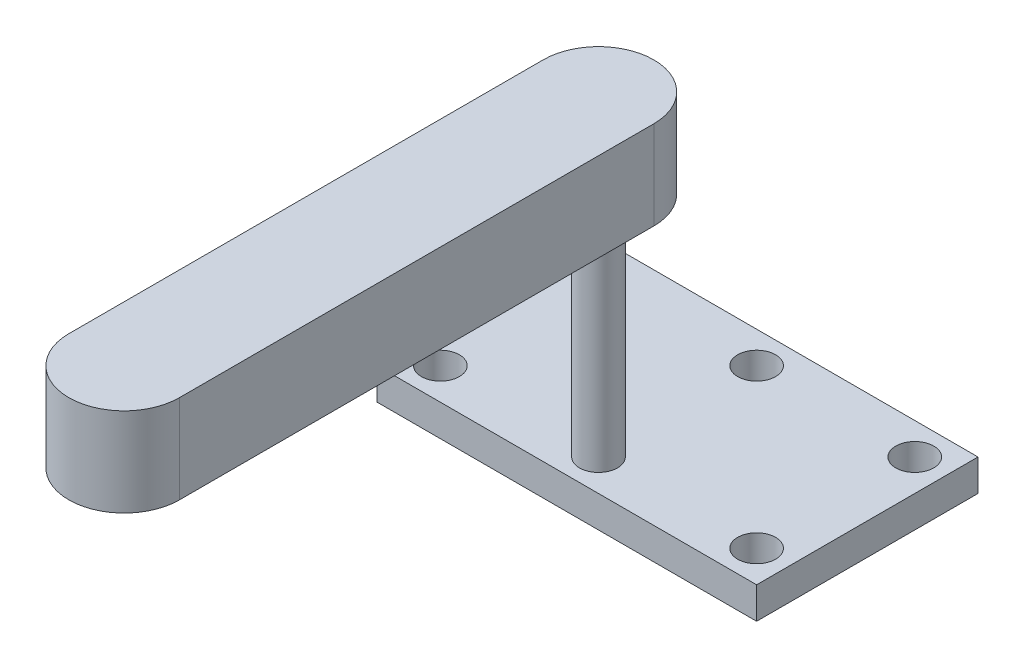
from build123d import *

# Parameters (mm, degrees)
SKETCH_1_W      = 60
SKETCH_1_H      = 35
SKETCH_1_R      = 3
EXTRUDE_1_DEPTH = 5
SKETCH_2_R      = 3
EXTRUDE_2_DEPTH = 55
EXTRUDE_3_DEPTH = 14


with BuildPart() as part:
    # 스케치1 → 보스-돌출1 (new body)
    with BuildSketch(Plane(origin=(0, 0, 0), x_dir=(1, 0, 0), z_dir=(0, 1, 0))):
        with Locations((0, 12.5)):
            Rectangle(SKETCH_1_W, SKETCH_1_H)
        Circle(SKETCH_1_R, mode=Mode.SUBTRACT)
        with Locations((25, 0)):
            Circle(SKETCH_1_R, mode=Mode.SUBTRACT)
        with Locations((-25, 0)):
            Circle(SKETCH_1_R, mode=Mode.SUBTRACT)
        with Locations((25, 25)):
            Circle(SKETCH_1_R, mode=Mode.SUBTRACT)
        with Locations((0, 25)):
            Circle(SKETCH_1_R, mode=Mode.SUBTRACT)
        with Locations((-25, 25)):
            Circle(SKETCH_1_R, mode=Mode.SUBTRACT)
    extrude(amount=EXTRUDE_1_DEPTH)

    # 스케치2 → 보스-돌출2 (add)
    with BuildSketch(Plane.XZ):
        Circle(SKETCH_2_R)
    extrude(amount=-EXTRUDE_2_DEPTH)

    # 스케치3 → 보스-돌출3 (add)
    with BuildSketch(Plane(origin=(0, 55, 0), x_dir=(1, 0, 0), z_dir=(0, 1, 0))):
        with BuildLine():
            Line((8.75, 0), (8.75, -75))
            ThreePointArc((8.75, -75), (0, -83.75), (-8.75, -75))
            Line((-8.75, -75), (-8.75, 0))
            ThreePointArc((-8.75, 0), (0, 8.75), (8.75, 0))
        make_face()
    extrude(amount=-EXTRUDE_3_DEPTH)


solid = part.part
